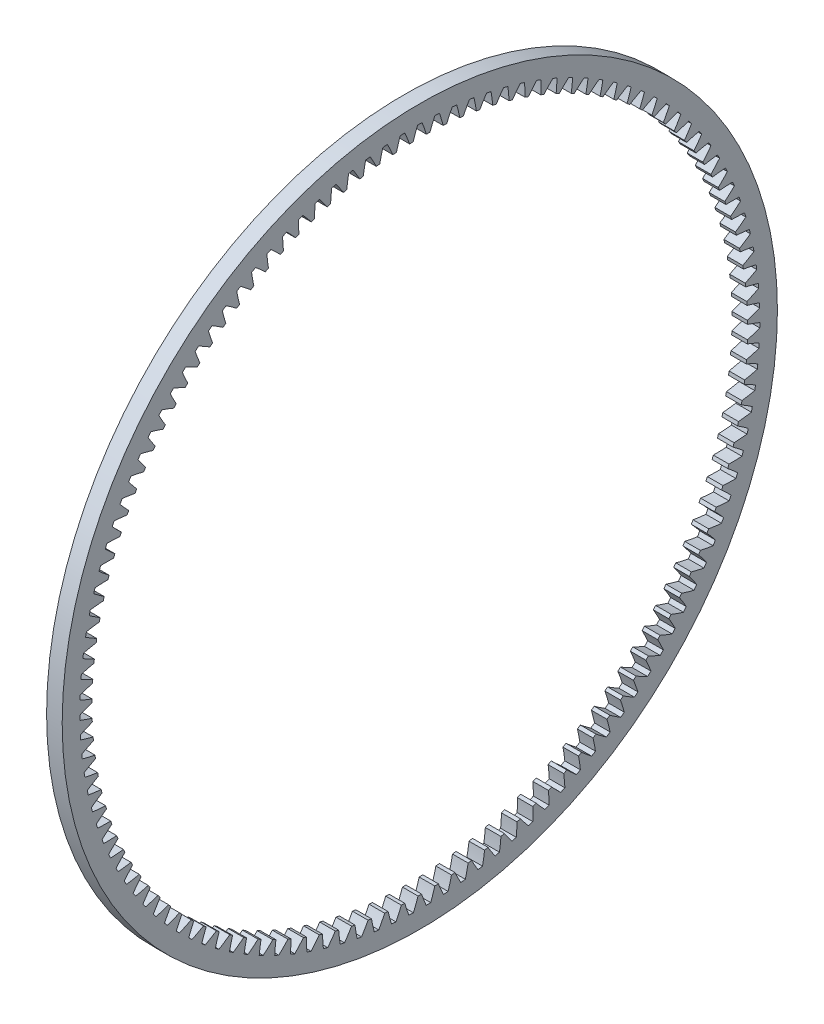
from build123d import *

# Parameters (mm, degrees)
BASPROSKE_W     = 3.048
BASPROSKE_H     = 5.820833333
TOOTHCUT_DEPTH  = 4.048
TEETHCUTS_COUNT = 123
TEETHCUTS_ANGLE = 357.073170732


with BuildPart() as part:
    # BasProSke → Base-Revolve (revolve)
    with BuildSketch(Plane(origin=(0, 0, 0), x_dir=(1, 0, 0), z_dir=(0, 1, 0))):
        with Locations((1.524, 66.939583333)):
            Rectangle(BASPROSKE_W, BASPROSKE_H)
    revolve(axis=Axis((-10, 0, 0), (1, 0, 0)))

    # TooCutSke → ToothCut (cut, through all)
    with BuildSketch(Plane(origin=(0, 0, 0), x_dir=(0, 0, -1), z_dir=(1, 0, 0))):
        with BuildLine():
            ThreePointArc((1.299005493, 63.990583153), (0.893202245, 65.207180263), (0.439779473, 66.406843796))
            ThreePointArc((0.439779473, 66.406843796), (0, 66.4083), (-0.439779473, 66.406843796))
            ThreePointArc((-0.439779473, 66.406843796), (-0.893202245, 65.207180263), (-1.299005493, 63.990583153))
            ThreePointArc((-1.299005493, 63.990583153), (0, 64.003766667), (1.299005493, 63.990583153))
        make_face()
    toothcut = extrude(amount=TOOTHCUT_DEPTH, mode=Mode.SUBTRACT)

    # TeethCuts: ToothCut ×123 about axis
    teethcuts_axis = Axis((-10, 0, 0), (1, 0, 0))
    for i in range(1, TEETHCUTS_COUNT):
        add(toothcut.rotate(teethcuts_axis, i * TEETHCUTS_ANGLE / (TEETHCUTS_COUNT - 1)), mode=Mode.SUBTRACT)


solid = part.part
